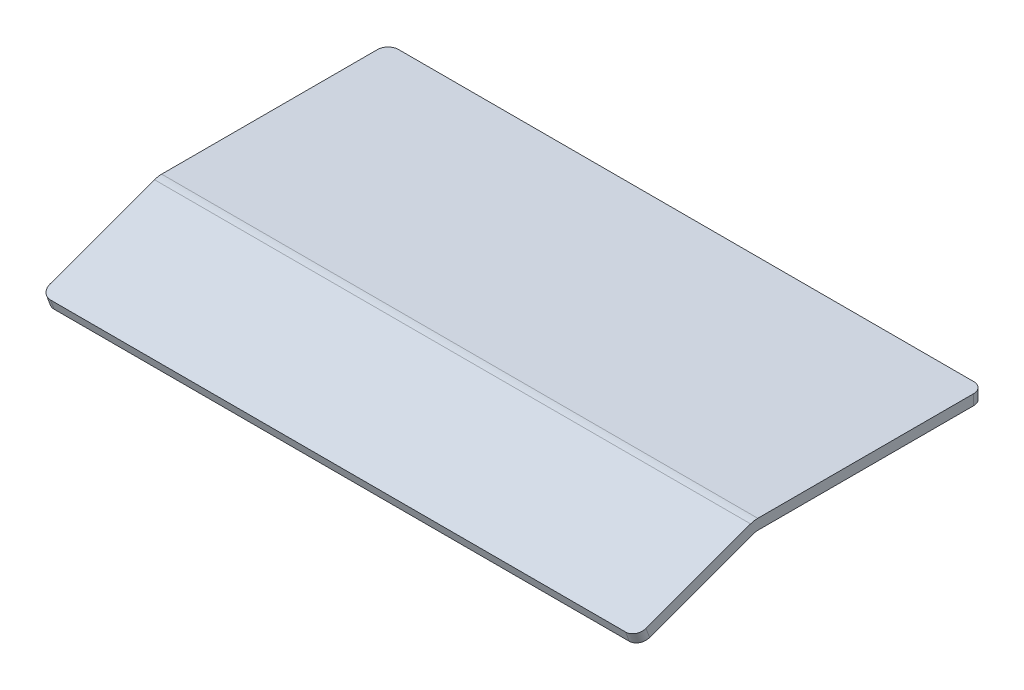
from build123d import *

# Parameters (mm, degrees)
BOSS_EXTRUDE1_DEPTH = 180.975
FILLET1_R           = 6.35


with BuildPart() as part:
    # Sketch1 → Boss-Extrude1 (new body, symmetric)
    with BuildSketch(Plane(origin=(0, 0, 0), x_dir=(0, 0, -1), z_dir=(1, 0, 0))):
        with BuildLine():
            ThreePointArc((-1.052151583, -0.382951858), (0.017010399, -0.096470768), (1.119676327, 0))
            Line((1.119676327, 0), (138.580323673, 0))
            Line((138.580323673, 0), (138.580323673, 6.35))
            Line((138.580323673, 6.35), (1.119676327, 6.35))
            ThreePointArc((1.119676327, 6.35), (-1.085655529, 6.157058463), (-3.223979493, 5.584096284))
            Line((-3.223979493, 5.584096284), (-72.724254031, -19.711934921))
            Line((-72.724254031, -19.711934921), (-70.552426121, -25.678983063))
            Line((-70.552426121, -25.678983063), (-1.052151583, -0.382951858))
        make_face()
    extrude(amount=BOSS_EXTRUDE1_DEPTH, both=True)

    # Fillet1
    fillet1_edges = [part.edges().sort_by_distance(p)[0] for p in [
        (-180.975, -22.695458992, 71.638340076),
        (180.975, -22.695458992, 71.638340076),
        (180.975, 3.175, -138.580323673),
        (-180.975, 3.175, -138.580323673),
    ]]
    fillet(fillet1_edges, radius=FILLET1_R)


solid = part.part
